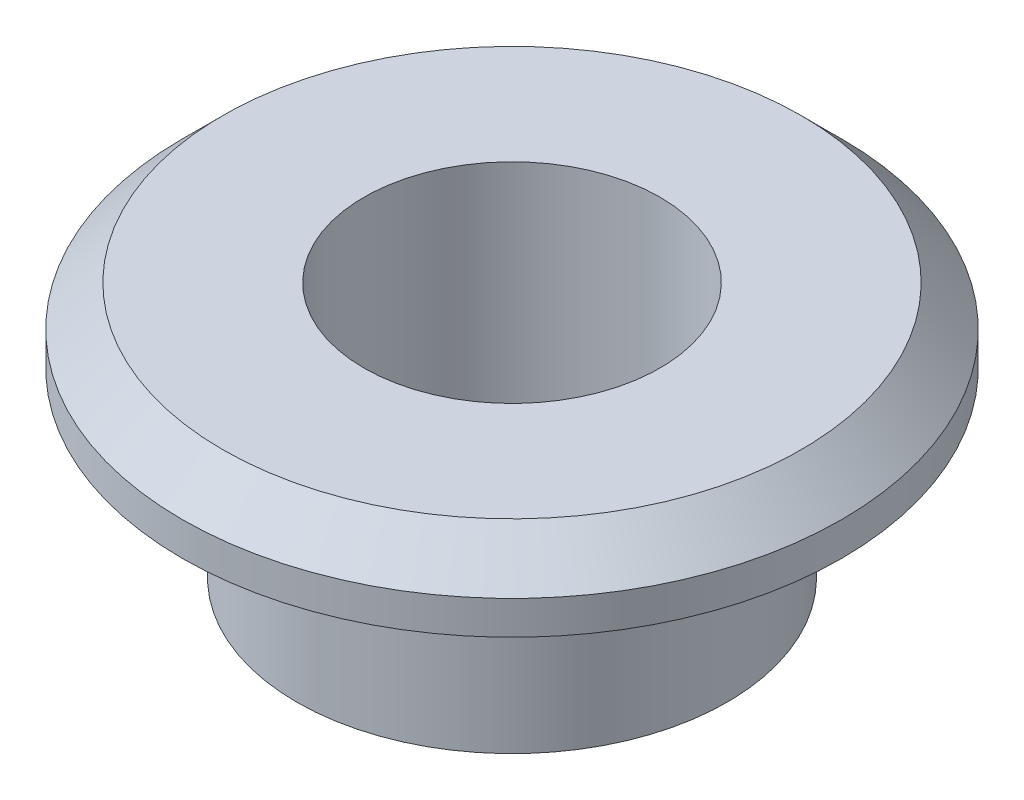
from build123d import *


with BuildPart() as part:
    # Sketch1 → Revolve1 (revolve)
    with BuildSketch(Plane.XY):
        Polygon((1.1, 1.9), (1.1, 0), (1.6, 0), (1.6, 1.35), (2.45, 1.35), (2.45, 1.6), (2.15, 1.9), align=None)
    revolve(axis=Axis((0, 9.791147956, 0), (0, -1, 0)))


solid = part.part
